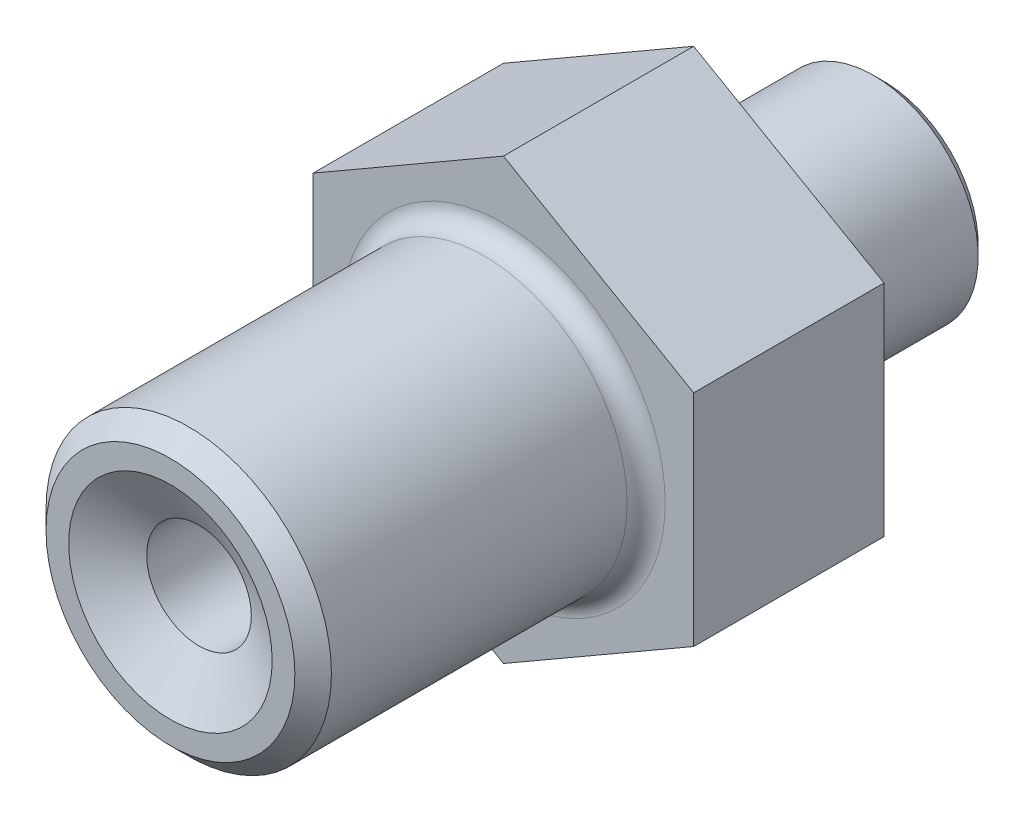
from build123d import *

# Parameters (mm, degrees)
SKETCH_1_R          = 17.5
EXTRUDE_1_DEPTH     = 20
SKETCH_2_R          = 15
EXTRUDE_2_DEPTH     = 35
SKETCH_3_R          = 11
EXTRUDE_3_DEPTH     = 20
CHAMFER_1_SIZE      = 1.1015
SKETCH_5_R          = 17.5
SKETCH_5_R_2        = 9.5
CUT_EXTRUDE_1_DEPTH = 2
CHAMFER_2_SIZE      = 1.921
FILLET_1_R          = 2
CHAMFER_3_SIZE      = 2
CHAMFER_3_SIZE2     = 1.154700538
SKETCH_6_R          = 17.5
EXTRUDE_4_DEPTH     = 20


with BuildPart() as part:
    # Эскиз1 → Бобышка-Вытянуть1 (new body)
    with BuildSketch(Plane.XY):
        Circle(SKETCH_1_R)
    extrude(amount=EXTRUDE_1_DEPTH)

    # Эскиз2 → Бобышка-Вытянуть2 (add)
    with BuildSketch(Plane.XY.offset(20)):
        Circle(SKETCH_2_R)
    extrude(amount=EXTRUDE_2_DEPTH)

    # Эскиз3 → Бобышка-Вытянуть3 (add)
    with BuildSketch(Plane(origin=(0, 0, 0), x_dir=(-1, 0, 0), z_dir=(0, 0, -1))):
        Circle(SKETCH_3_R)
    extrude(amount=EXTRUDE_3_DEPTH)

    # Эскиз4 → Вырез-Повернуть1 (revolve, cut)
    with BuildSketch(Plane(origin=(0, 0, 0), x_dir=(0, 0, -1), z_dir=(1, 0, 0))):
        Polygon((-55, 0), (-55, 10.696152423), (-52, 5.5), (20, 5.5), (20, 0), align=None)
    revolve(axis=Axis((0, 0, 55), (0, 0, -1)), mode=Mode.SUBTRACT)

    # Фаска1
    chamfer_1_edges = [part.edges().sort_by_distance(p)[0] for p in [
        (11, 0, -20),
    ]]
    chamfer(chamfer_1_edges, length=CHAMFER_1_SIZE)

    # Эскиз5 → Вырез-Вытянуть1 (cut)
    with BuildSketch(Plane(origin=(0, 0, 0), x_dir=(-1, 0, 0), z_dir=(0, 0, -1))):
        Circle(SKETCH_5_R)
        Circle(SKETCH_5_R_2, mode=Mode.SUBTRACT)
    extrude(amount=CUT_EXTRUDE_1_DEPTH, mode=Mode.SUBTRACT)

    # Фаска2
    chamfer_2_edges = [part.edges().sort_by_distance(p)[0] for p in [
        (-15, 0, 55),
    ]]
    chamfer(chamfer_2_edges, length=CHAMFER_2_SIZE)

    # Скругление1
    fillet_1_edges = [part.edges().sort_by_distance(p)[0] for p in [
        (-15, 0, 20),
    ]]
    fillet(fillet_1_edges, radius=FILLET_1_R)

    # Фаска3
    chamfer_3_edges = [part.edges().sort_by_distance(p)[0] for p in [
        (0, -5.5, -20),
    ]]
    chamfer_3_side = [part.faces().sort_by_distance(p)[0] for p in [
        (0, -5.5, 16),
    ]]
    chamfer(chamfer_3_edges, length=CHAMFER_3_SIZE, length2=CHAMFER_3_SIZE2, reference=chamfer_3_side[0])

    # Эскиз6 → Бобышка-Вытянуть4 (add)
    with BuildSketch(Plane(origin=(0, 0, 0), x_dir=(-1, 0, 0), z_dir=(0, 0, -1))):
        Polygon((0, 23.094010768), (-20, 11.547005384), (-20, -11.547005384), (0, -23.094010768), (20, -11.547005384), (20, 11.547005384), align=None)
        Circle(SKETCH_6_R, mode=Mode.SUBTRACT)
    extrude(amount=-EXTRUDE_4_DEPTH)


solid = part.part
